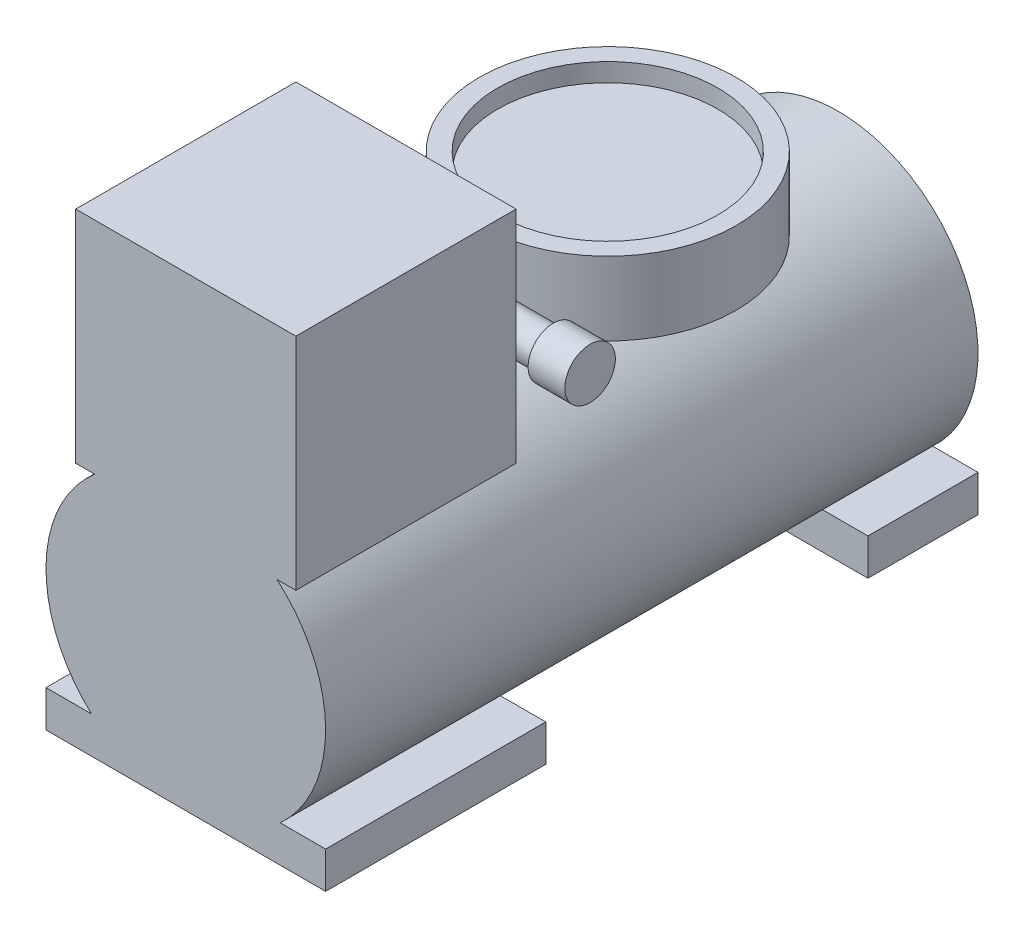
from build123d import *

# Parameters (mm, degrees)
SKETCH1_R           = 38.1
BOSS_EXTRUDE1_DEPTH = 177.8
SKETCH2_W           = 60
SKETCH2_H           = 60
SKETCH2_W_2         = 76.2
SKETCH2_H_2         = 10
BOSS_EXTRUDE2_DEPTH = 60
SKETCH3_R           = 5
BOSS_EXTRUDE3_DEPTH = 20
SKETCH4_W           = 70
SKETCH4_H           = 20
BOSS_EXTRUDE4_DEPTH = 70
CUT_EXTRUDE3_DEPTH  = 22
SKETCH6_R           = 30
CUT_EXTRUDE4_DEPTH  = 5
BOSS_EXTRUDE5_DEPTH = 30
SKETCH8_R           = 5
BOSS_EXTRUDE6_DEPTH = 40
SKETCH9_R           = 6.895484993
BOSS_EXTRUDE7_DEPTH = 10


with BuildPart() as part:
    # Sketch1 → Boss-Extrude1 (new body)
    with BuildSketch(Plane.XY):
        Circle(SKETCH1_R)
    extrude(amount=BOSS_EXTRUDE1_DEPTH)

    # Sketch2 → Boss-Extrude2 (add)
    with BuildSketch(Plane.XY.offset(177.8)):
        with Locations((0, 58.9)):
            Rectangle(SKETCH2_W, SKETCH2_H)
        with Locations((0, -33.1)):
            Rectangle(SKETCH2_W_2, SKETCH2_H_2)
    extrude(amount=-BOSS_EXTRUDE2_DEPTH)

    # Sketch3 → Boss-Extrude3 (add)
    with BuildSketch(Plane(origin=(0, 0, 117.8), x_dir=(-1, 0, 0), z_dir=(0, 0, -1))):
        with Locations((0, 50)):
            Circle(SKETCH3_R)
    extrude(amount=BOSS_EXTRUDE3_DEPTH)

    # Sketch4 → Boss-Extrude4 (add)
    with BuildSketch(Plane(origin=(0, 0, 97.8), x_dir=(-1, 0, 0), z_dir=(0, 0, -1))):
        with Locations((0, 50)):
            Rectangle(SKETCH4_W, SKETCH4_H)
    extrude(amount=BOSS_EXTRUDE4_DEPTH)

    # Sketch5 → Cut-Extrude3 (cut)
    with BuildSketch(Plane(origin=(0, 60, 0), x_dir=(1, 0, 0), z_dir=(0, 1, 0))):
        with BuildLine():
            Line((-5, -106.177349964), (-48.741925114, -106.177349964))
            Line((-48.741925114, -106.177349964), (-48.741925114, -19.422650036))
            Line((-48.741925114, -19.422650036), (48.741925114, -19.422650036))
            Line((48.741925114, -19.422650036), (48.741925114, -106.177349964))
            Line((48.741925114, -106.177349964), (5, -106.177349964))
            Line((5, -106.177349964), (5, -97.441016151))
            ThreePointArc((5, -97.441016151), (0, -27.8), (-5, -97.441016151))
            Line((-5, -97.441016151), (-5, -106.177349964))
        make_face()
    extrude(amount=-CUT_EXTRUDE3_DEPTH, mode=Mode.SUBTRACT)

    # Sketch6 → Cut-Extrude4 (cut)
    with BuildSketch(Plane(origin=(0, 60, 0), x_dir=(1, 0, 0), z_dir=(0, 1, 0))):
        with Locations((0, -62.8)):
            Circle(SKETCH6_R)
    extrude(amount=-CUT_EXTRUDE4_DEPTH, mode=Mode.SUBTRACT)

    # Sketch7 → Boss-Extrude5 (add)
    with BuildSketch(Plane(origin=(0, 0, 0), x_dir=(-1, 0, 0), z_dir=(0, 0, -1))):
        with BuildLine():
            Line((-38.1, -38.1), (0, -38.1))
            ThreePointArc((0, -38.1), (-13.802173742, -35.51211061), (-25.729360661, -28.1))
            Line((-25.729360661, -28.1), (-38.1, -28.1))
            Line((-38.1, -28.1), (-38.1, -38.1))
        make_face()
        with BuildLine():
            Line((38.1, -38.1), (38.1, -28.1))
            Line((38.1, -28.1), (25.729360661, -28.1))
            ThreePointArc((25.729360661, -28.1), (13.802173742, -35.51211061), (0, -38.1))
            Line((0, -38.1), (38.1, -38.1))
        make_face()
    extrude(amount=-BOSS_EXTRUDE5_DEPTH)

    # Sketch8 → Boss-Extrude6 (add)
    with BuildSketch(Plane(origin=(0, 0, 0), x_dir=(0, 0, -1), z_dir=(1, 0, 0))):
        with Locations((-107.620508076, 50)):
            Circle(SKETCH8_R)
    extrude(amount=BOSS_EXTRUDE6_DEPTH)

    # Sketch9 → Boss-Extrude7 (add)
    with BuildSketch(Plane(origin=(40, 0, 0), x_dir=(0, 0, -1), z_dir=(1, 0, 0))):
        with Locations((-107.620508076, 50)):
            Circle(SKETCH9_R)
    extrude(amount=-BOSS_EXTRUDE7_DEPTH)


solid = part.part
